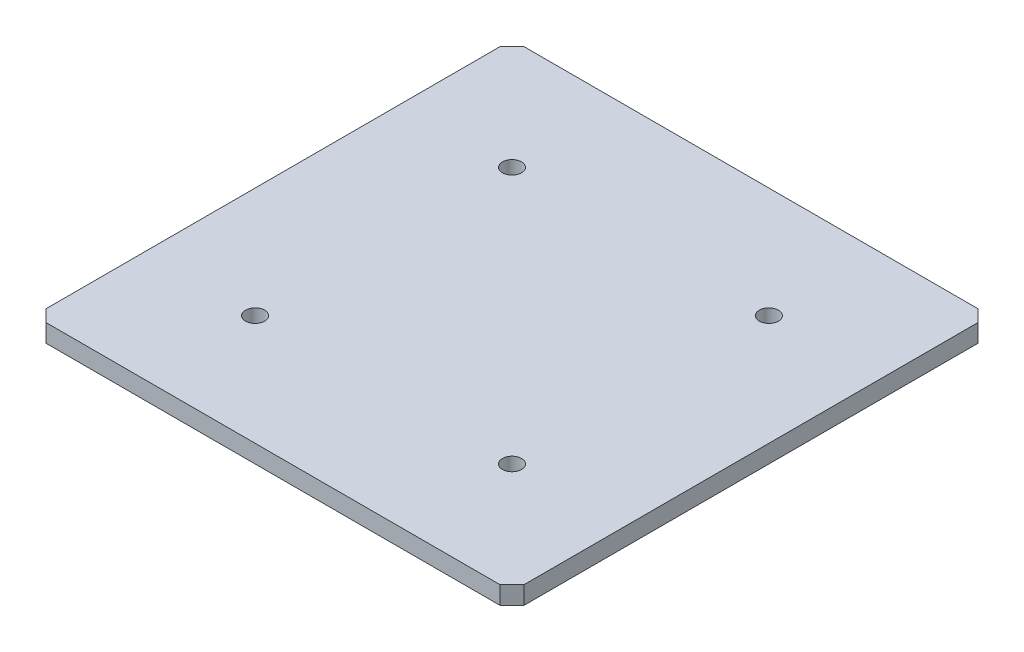
from build123d import *

# Parameters (mm, degrees)
SKETCH1_W           = 400
SKETCH1_H           = 400
BOSS_EXTRUDE1_DEPTH = 7.5
CHAMFER1_SIZE       = 10
SKETCH3_R           = 8
CUT_EXTRUDE1_DEPTH  = 16


with BuildPart() as part:
    # Sketch1 → Boss-Extrude1 (new body, symmetric)
    with BuildSketch(Plane(origin=(0, 0, 0), x_dir=(1, 0, 0), z_dir=(0, 1, 0))):
        with Locations((200, 200)):
            Rectangle(SKETCH1_W, SKETCH1_H)
    extrude(amount=BOSS_EXTRUDE1_DEPTH, both=True)

    # Chamfer1
    chamfer1_edges = [part.edges().sort_by_distance(p)[0] for p in [
        (0, 0, -400),
        (400, 0, -400),
        (400, 0, 0),
        (0, 0, 0),
    ]]
    chamfer(chamfer1_edges, length=CHAMFER1_SIZE)

    # Sketch3 → Cut-Extrude1 (cut)
    with BuildSketch(Plane(origin=(0, 7.5, 0), x_dir=(1, 0, 0), z_dir=(0, 1, 0))):
        with Locations((307.5, 307.5)):
            Circle(SKETCH3_R)
        with Locations((307.5, 92.5)):
            Circle(SKETCH3_R)
        with Locations((92.5, 92.5)):
            Circle(SKETCH3_R)
        with Locations((92.5, 307.5)):
            Circle(SKETCH3_R)
    extrude(amount=-CUT_EXTRUDE1_DEPTH, mode=Mode.SUBTRACT)


solid = part.part
